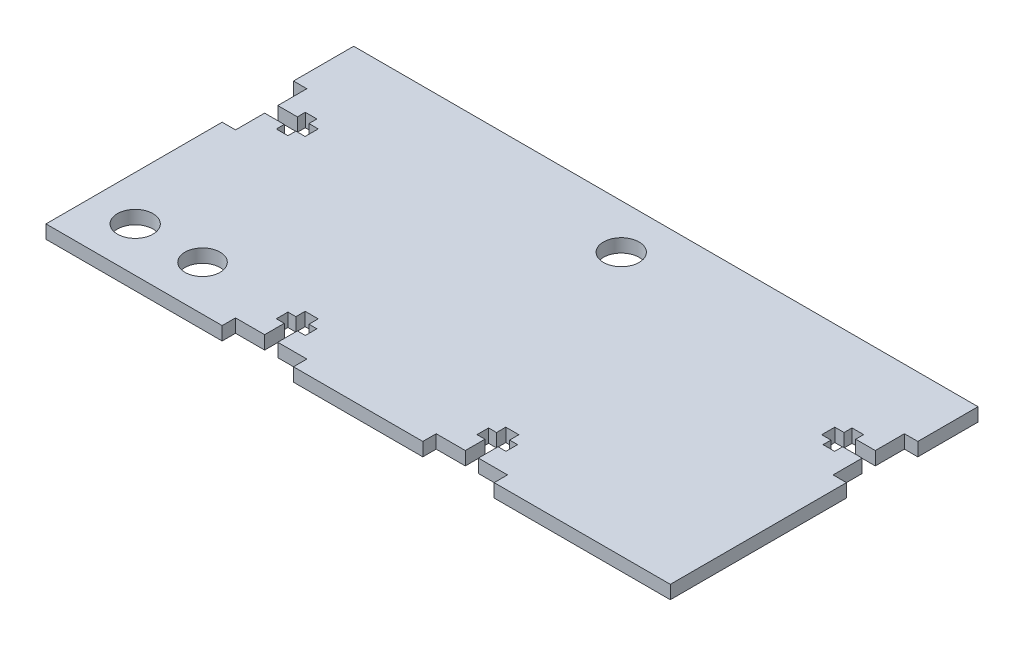
from build123d import *

# Parameters (mm, degrees)
SKETCH1_W           = 140
SKETCH1_H           = 140
BOSS_EXTRUDE1_DEPTH = 3
SKETCH2_W           = 16
SKETCH2_H           = 3
SKETCH2_W_2         = 3
SKETCH2_H_2         = 16
CUT_EXTRUDE1_DEPTH  = 3
SKETCH3_W           = 3
SKETCH3_H           = 10
CUT_EXTRUDE2_DEPTH  = 10
SKETCH4_W           = 3
SKETCH4_H           = 10
CUT_EXTRUDE3_DEPTH  = 3
CUT_EXTRUDE4_DEPTH  = 3
CUT_EXTRUDE5_DEPTH  = 3
BOSS_EXTRUDE4_DEPTH = 3
BOSS_EXTRUDE5_DEPTH = 3
SKETCH12_W          = 3
SKETCH12_H          = 3
BOSS_EXTRUDE6_DEPTH = 3
SKETCH13_W          = 3
SKETCH13_H          = 3
BOSS_EXTRUDE7_DEPTH = 3
BOSS_EXTRUDE8_DEPTH = 3
SKETCH15_W          = 140
SKETCH15_H          = 1
CUT_EXTRUDE6_DEPTH  = 3
SKETCH16_W          = 140
SKETCH16_H          = 70
CUT_EXTRUDE8_DEPTH  = 3
SKETCH17_R          = 3.99
CUT_EXTRUDE11_DEPTH = 3
SKETCH18_R          = 3.935
CUT_EXTRUDE12_DEPTH = 3


with BuildPart() as part:
    # Sketch1 → Boss-Extrude1 (new body)
    with BuildSketch(Plane(origin=(0, 0, 0), x_dir=(1, 0, 0), z_dir=(0, 1, 0))):
        Rectangle(SKETCH1_W, SKETCH1_H)
    extrude(amount=BOSS_EXTRUDE1_DEPTH)

    # Sketch2 → Cut-Extrude1 (cut)
    with BuildSketch(Plane(origin=(0, 3, 0), x_dir=(1, 0, 0), z_dir=(0, 1, 0))):
        with Locations((-22.5, 68.5)):
            Rectangle(SKETCH2_W, SKETCH2_H)
        with Locations((-22.5, -68.5)):
            Rectangle(SKETCH2_W, SKETCH2_H)
        with Locations((22.5, -68.5)):
            Rectangle(SKETCH2_W, SKETCH2_H)
        with Locations((22.5, 68.5)):
            Rectangle(SKETCH2_W, SKETCH2_H)
        with Locations((-68.5, 22.5)):
            Rectangle(SKETCH2_W_2, SKETCH2_H_2)
        with Locations((-68.5, -22.5)):
            Rectangle(SKETCH2_W_2, SKETCH2_H_2)
        with Locations((68.5, -22.5)):
            Rectangle(SKETCH2_W_2, SKETCH2_H_2)
        with Locations((68.5, 22.5)):
            Rectangle(SKETCH2_W_2, SKETCH2_H_2)
    extrude(amount=-CUT_EXTRUDE1_DEPTH, mode=Mode.SUBTRACT)

    # Sketch3 → Cut-Extrude2 (cut)
    with BuildSketch(Plane(origin=(0, 3, 0), x_dir=(1, 0, 0), z_dir=(0, 1, 0))):
        with Locations((-68.5, 65)):
            Rectangle(SKETCH3_W, SKETCH3_H)
    extrude(amount=-CUT_EXTRUDE2_DEPTH, mode=Mode.SUBTRACT)

    # Sketch4 → Cut-Extrude3 (cut)
    with BuildSketch(Plane(origin=(0, 3, 0), x_dir=(1, 0, 0), z_dir=(0, 1, 0))):
        with Locations((68.5, 65)):
            Rectangle(SKETCH4_W, SKETCH4_H)
    extrude(amount=-CUT_EXTRUDE3_DEPTH, mode=Mode.SUBTRACT)

    # Sketch5 → Cut-Extrude4 (cut)
    with BuildSketch(Plane(origin=(0, 3, 0), x_dir=(1, 0, 0), z_dir=(0, 1, 0))):
        Polygon((-21.03, 67), (-23.97, 67), (-23.97, 62.6), (-25.75, 62.6), (-25.75, 60), (-23.97, 60), (-23.97, 57.92), (-21.03, 57.92), (-21.03, 60), (-19.25, 60), (-19.25, 62.6), (-21.03, 62.6), align=None)
        Polygon((-21.03, -67), (-21.03, -62.6), (-19.25, -62.6), (-19.25, -60), (-21.03, -60), (-21.03, -57.92), (-23.97, -57.92), (-23.97, -60), (-25.75, -60), (-25.75, -62.6), (-23.97, -62.6), (-23.97, -67), align=None)
        Polygon((21.03, 67), (21.03, 62.6), (19.25, 62.6), (19.25, 60), (21.03, 60), (21.03, 57.92), (23.97, 57.92), (23.97, 60), (25.75, 60), (25.75, 62.6), (23.97, 62.6), (23.97, 67), align=None)
        Polygon((21.03, -67), (23.97, -67), (23.97, -62.6), (25.75, -62.6), (25.75, -60), (23.97, -60), (23.97, -57.92), (21.03, -57.92), (21.03, -60), (19.25, -60), (19.25, -62.6), (21.03, -62.6), align=None)
    extrude(amount=-CUT_EXTRUDE4_DEPTH, mode=Mode.SUBTRACT)

    # Sketch6 → Cut-Extrude5 (cut)
    with BuildSketch(Plane(origin=(0, 3, 0), x_dir=(1, 0, 0), z_dir=(0, 1, 0))):
        Polygon((67, -21.03), (67, -23.97), (62.6, -23.97), (62.6, -25.75), (60, -25.75), (60, -23.97), (57.92, -23.97), (57.92, -21.03), (60, -21.03), (60, -19.25), (62.6, -19.25), (62.6, -21.03), align=None)
        Polygon((67, 21.03), (62.6, 21.03), (62.6, 19.25), (60, 19.25), (60, 21.03), (57.92, 21.03), (57.92, 23.97), (60, 23.97), (60, 25.75), (62.6, 25.75), (62.6, 23.97), (67, 23.97), align=None)
        Polygon((-67, -21.03), (-62.6, -21.03), (-62.6, -19.25), (-60, -19.25), (-60, -21.03), (-57.92, -21.03), (-57.92, -23.97), (-60, -23.97), (-60, -25.75), (-62.6, -25.75), (-62.6, -23.97), (-67, -23.97), align=None)
        Polygon((-67, 21.03), (-67, 23.97), (-62.6, 23.97), (-62.6, 25.75), (-60, 25.75), (-60, 23.97), (-57.92, 23.97), (-57.92, 21.03), (-60, 21.03), (-60, 19.25), (-62.6, 19.25), (-62.6, 21.03), align=None)
    extrude(amount=-CUT_EXTRUDE5_DEPTH, mode=Mode.SUBTRACT)

    # Sketch8 → Boss-Extrude4 (add)
    with BuildSketch(Plane(origin=(0, 3, 0), x_dir=(1, 0, 0), z_dir=(0, 1, 0))):
        Polygon((-70, 30.5), (-67, 30.5), (-67, 23.97), (-62.6, 23.97), (-62.6, 25.75), (-60, 25.75), (-60, 23.97), (-57.92, 23.97), (-57.92, 21.03), (-60, 21.03), (-60, 19.25), (-62.6, 19.25), (-62.6, 21.03), (-67, 21.03), (-67, 14.5), (-70, 14.5), align=None)
    extrude(amount=-BOSS_EXTRUDE4_DEPTH)

    # Sketch10 → Boss-Extrude5 (add)
    with BuildSketch(Plane(origin=(0, 3, 0), x_dir=(1, 0, 0), z_dir=(0, 1, 0))):
        Polygon((70, 30.5), (67, 30.5), (67, 23.97), (62.6, 23.97), (62.6, 25.75), (60, 25.75), (60, 23.97), (57.92, 23.97), (57.92, 21.03), (60, 21.03), (60, 19.25), (62.6, 19.25), (62.6, 21.03), (67, 21.03), (67, 14.5), (70, 14.5), align=None)
    extrude(amount=-BOSS_EXTRUDE5_DEPTH)

    # Sketch12 → Boss-Extrude6 (add)
    with BuildSketch(Plane(origin=(0, 3, 0), x_dir=(1, 0, 0), z_dir=(0, 1, 0))):
        with Locations((-68.5, 68.5)):
            Rectangle(SKETCH12_W, SKETCH12_H)
    extrude(amount=-BOSS_EXTRUDE6_DEPTH)

    # Sketch13 → Boss-Extrude7 (add)
    with BuildSketch(Plane(origin=(0, 3, 0), x_dir=(1, 0, 0), z_dir=(0, 1, 0))):
        with Locations((68.5, 68.5)):
            Rectangle(SKETCH13_W, SKETCH13_H)
    extrude(amount=-BOSS_EXTRUDE7_DEPTH)

    # Sketch14 → Boss-Extrude8 (add)
    with BuildSketch(Plane(origin=(0, 3, 0), x_dir=(1, 0, 0), z_dir=(0, 1, 0))):
        Polygon((-30.5, 70), (-14.5, 70), (-14.5, 67), (-21.03, 67), (-21.03, 62.6), (-19.25, 62.6), (-19.25, 60), (-21.03, 60), (-21.03, 57.92), (-23.97, 57.92), (-23.97, 60), (-25.75, 60), (-25.75, 62.6), (-23.97, 62.6), (-23.97, 67), (-30.5, 67), align=None)
        Polygon((14.5, 70), (30.5, 70), (30.5, 67), (23.97, 67), (23.97, 62.6), (25.75, 62.6), (25.75, 60), (23.97, 60), (23.97, 57.92), (21.03, 57.92), (21.03, 60), (19.25, 60), (19.25, 62.6), (21.03, 62.6), (21.03, 67), (14.5, 67), align=None)
    extrude(amount=-BOSS_EXTRUDE8_DEPTH)

    # Sketch15 → Cut-Extrude6 (cut)
    with BuildSketch(Plane(origin=(0, 3, 0), x_dir=(1, 0, 0), z_dir=(0, 1, 0))):
        with Locations((0, -0.5)):
            Rectangle(SKETCH15_W, SKETCH15_H)
    extrude(amount=-CUT_EXTRUDE6_DEPTH, mode=Mode.SUBTRACT)

    # Sketch16 → Cut-Extrude8 (cut)
    with BuildSketch(Plane(origin=(0, 3, 0), x_dir=(1, 0, 0), z_dir=(0, 1, 0))):
        with Locations((0, 35)):
            Rectangle(SKETCH16_W, SKETCH16_H)
    extrude(amount=-CUT_EXTRUDE8_DEPTH, mode=Mode.SUBTRACT)

    # Sketch17 → Cut-Extrude11 (cut)
    with BuildSketch(Plane(origin=(0, 3, 0), x_dir=(1, 0, 0), z_dir=(0, 1, 0))):
        with Locations((0, -11)):
            Circle(SKETCH17_R)
        with Locations((-60, -60)):
            Circle(SKETCH17_R)
    extrude(amount=-CUT_EXTRUDE11_DEPTH, mode=Mode.SUBTRACT)

    # Sketch18 → Cut-Extrude12 (cut)
    with BuildSketch(Plane(origin=(0, 3, 0), x_dir=(1, 0, 0), z_dir=(0, 1, 0))):
        with Locations((-45, -59.9)):
            Circle(SKETCH18_R)
    extrude(amount=-CUT_EXTRUDE12_DEPTH, mode=Mode.SUBTRACT)


solid = part.part
